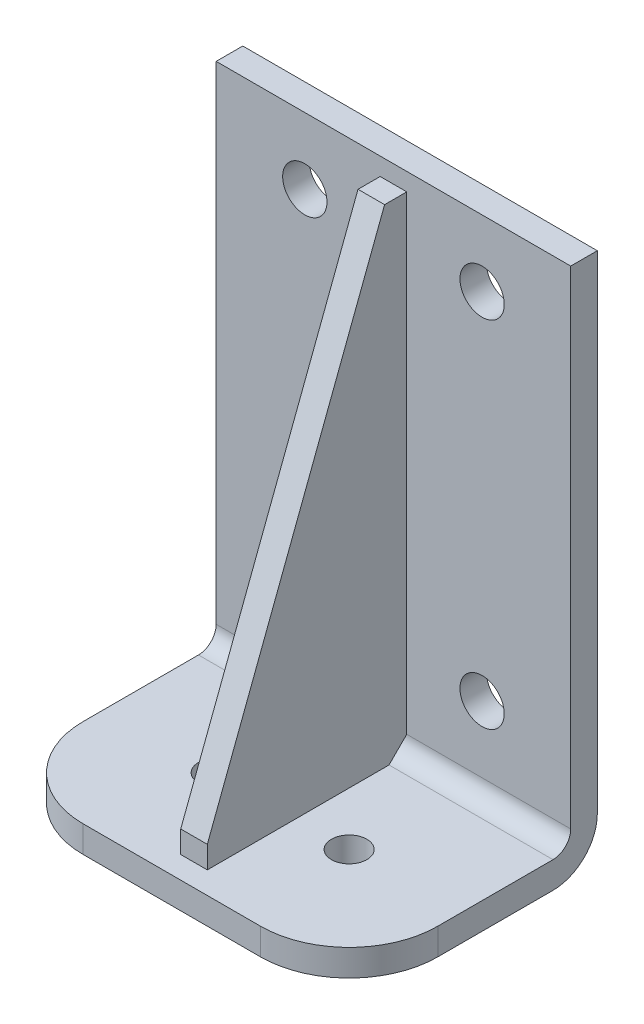
from build123d import *

# Parameters (mm, degrees)
SKETCH_1_W          = 80
SKETCH_1_H          = 120
EXTRUDE_1_DEPTH     = 6
SKETCH_2_W          = 80
SKETCH_2_H          = 6
EXTRUDE_2_DEPTH     = 50
FILLET_1_R          = 4
FILLET_2_R          = 10
CUT_EXTRUDE_1_REACH = 8
SKETCH_3_R          = 5
EXTRUDE_3_DEPTH     = 3
SKETCH_5_R          = 4
CUT_EXTRUDE_2_DEPTH = 6
FILLET_3_R          = 20


with BuildPart() as part:
    # 草图1 → 凸台-拉伸1 (new body)
    with BuildSketch(Plane.XY):
        with Locations((40, 60)):
            Rectangle(SKETCH_1_W, SKETCH_1_H)
    extrude(amount=EXTRUDE_1_DEPTH)

    # 草图2 → 凸台-拉伸2 (add)
    with BuildSketch(Plane.XY.offset(6)):
        with Locations((40, 3)):
            Rectangle(SKETCH_2_W, SKETCH_2_H)
    extrude(amount=EXTRUDE_2_DEPTH)

    # 圆角1
    fillet_1_edges = [part.edges().sort_by_distance(p)[0] for p in [
        (40, 6, 6),
    ]]
    fillet(fillet_1_edges, radius=FILLET_1_R)

    # 圆角2
    fillet_2_edges = [part.edges().sort_by_distance(p)[0] for p in [
        (40, 0, 0),
    ]]
    fillet(fillet_2_edges, radius=FILLET_2_R)

    # 草图3 → 切除-拉伸1 (cut, up to next)
    with BuildSketch(Plane.XY.offset(6), mode=Mode.PRIVATE) as cut_extrude_1_sk1:
        with Locations((60, 105)):
            Circle(SKETCH_3_R)
    cut_extrude_1_tool1 = extrude(cut_extrude_1_sk1.sketch, amount=-CUT_EXTRUDE_1_REACH, mode=Mode.PRIVATE) & part.part
    add(cut_extrude_1_tool1.solids().sort_by_distance((60, 105, 6))[0], mode=Mode.SUBTRACT)
    # 草图3 → 切除-拉伸1 (cut, up to next)
    with BuildSketch(Plane.XY.offset(6), mode=Mode.PRIVATE) as cut_extrude_1_sk2:
        with Locations((20, 105)):
            Circle(SKETCH_3_R)
    cut_extrude_1_tool2 = extrude(cut_extrude_1_sk2.sketch, amount=-CUT_EXTRUDE_1_REACH, mode=Mode.PRIVATE) & part.part
    add(cut_extrude_1_tool2.solids().sort_by_distance((20, 105, 6))[0], mode=Mode.SUBTRACT)
    # 草图3 → 切除-拉伸1 (cut, up to next)
    with BuildSketch(Plane.XY.offset(6), mode=Mode.PRIVATE) as cut_extrude_1_sk3:
        with Locations((20, 25)):
            Circle(SKETCH_3_R)
    cut_extrude_1_tool3 = extrude(cut_extrude_1_sk3.sketch, amount=-CUT_EXTRUDE_1_REACH, mode=Mode.PRIVATE) & part.part
    add(cut_extrude_1_tool3.solids().sort_by_distance((20, 25, 6))[0], mode=Mode.SUBTRACT)
    # 草图3 → 切除-拉伸1 (cut, up to next)
    with BuildSketch(Plane.XY.offset(6), mode=Mode.PRIVATE) as cut_extrude_1_sk4:
        with Locations((60, 25)):
            Circle(SKETCH_3_R)
    cut_extrude_1_tool4 = extrude(cut_extrude_1_sk4.sketch, amount=-CUT_EXTRUDE_1_REACH, mode=Mode.PRIVATE) & part.part
    add(cut_extrude_1_tool4.solids().sort_by_distance((60, 25, 6))[0], mode=Mode.SUBTRACT)

    # 草图4 → 凸台-拉伸3 (add, symmetric)
    with BuildSketch(Plane(origin=(40, 0, 0), x_dir=(0, 0, -1), z_dir=(1, 0, 0))):
        Polygon((-51, 6), (-10, 6), (-6, 10), (-6, 116), (-11, 116), (-51, 11), align=None)
    extrude(amount=EXTRUDE_3_DEPTH, both=True)

    # 草图5 → 切除-拉伸2 (cut)
    with BuildSketch(Plane(origin=(0, 6, 0), x_dir=(1, 0, 0), z_dir=(0, 1, 0))):
        with Locations((25, -31)):
            Circle(SKETCH_5_R)
        with Locations((55, -31)):
            Circle(SKETCH_5_R)
    extrude(amount=-CUT_EXTRUDE_2_DEPTH, mode=Mode.SUBTRACT)

    # 圆角3
    fillet_3_edges = [part.edges().sort_by_distance(p)[0] for p in [
        (0, 3, 56),
        (80, 3, 56),
    ]]
    fillet(fillet_3_edges, radius=FILLET_3_R)


solid = part.part
